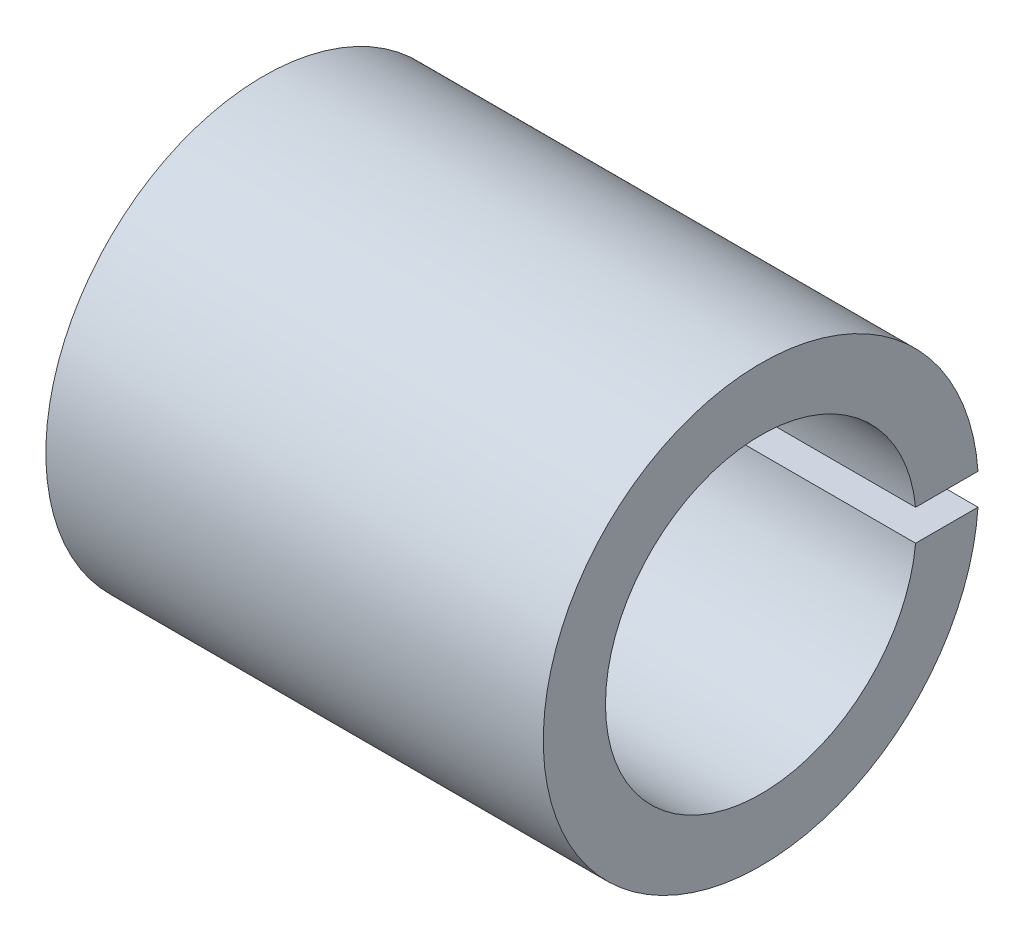
from build123d import *

# Parameters (mm, degrees)
BOSS_EXTRUDE1_DEPTH = 8


with BuildPart() as part:
    # Sketch1 → Boss-Extrude1 (new body, symmetric)
    with BuildSketch(Plane(origin=(0, 0, 0), x_dir=(0, 0, -1), z_dir=(1, 0, 0))):
        with BuildLine():
            Line((4.974937186, 0.5), (6.982120022, 0.5))
            ThreePointArc((6.982120022, 0.5), (-7, 0), (6.982120022, -0.5))
            Line((6.982120022, -0.5), (4.974937186, -0.5))
            ThreePointArc((4.974937186, -0.5), (-5, 0), (4.974937186, 0.5))
        make_face()
    extrude(amount=BOSS_EXTRUDE1_DEPTH, both=True)


solid = part.part
